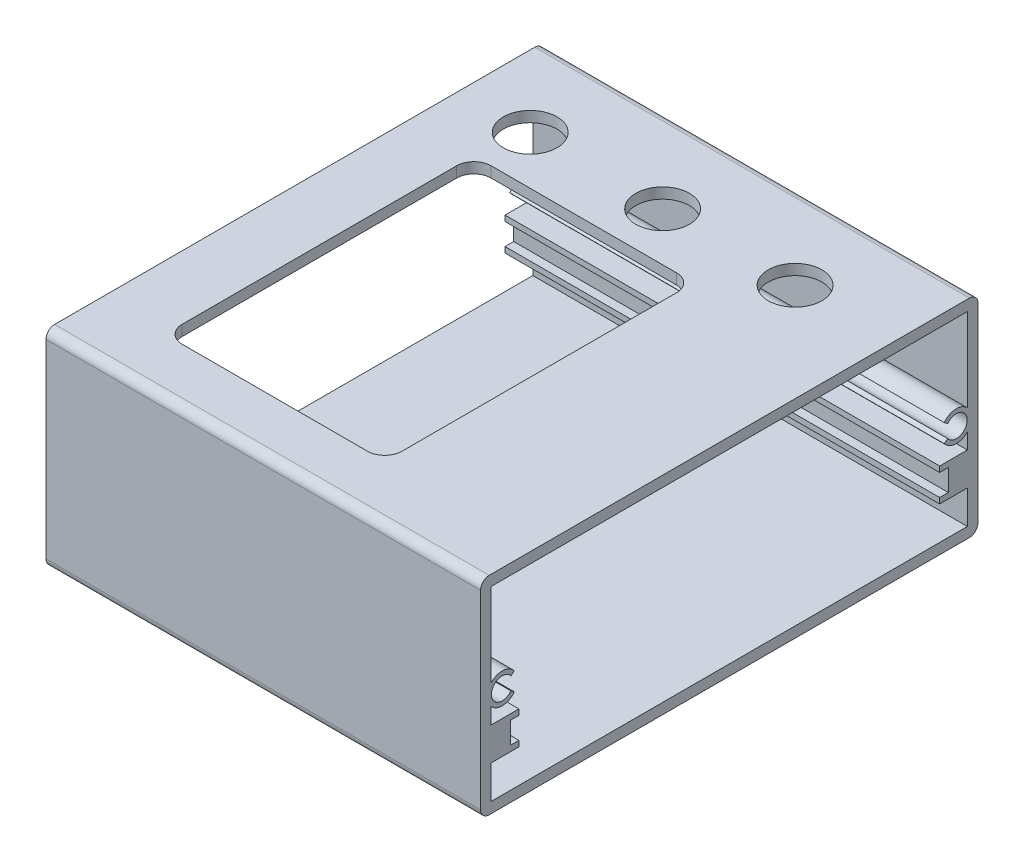
from build123d import *

# Parameters (mm, degrees)
SKETCH1_W           = 57.46
SKETCH1_H           = 23.96
BOSS_EXTRUDE1_DEPTH = 50.2
FILLET1_R           = 1
CUT_EXTRUDE1_REACH  = 25.96
SKETCH2_R           = 3.1
SKETCH2_R_2         = 3
CUT_EXTRUDE2_REACH  = 25.96


with BuildPart() as part:
    # Sketch1 → Boss-Extrude1 (new body)
    with BuildSketch(Plane(origin=(0, 0, 0), x_dir=(0, 0, -1), z_dir=(1, 0, 0))):
        Rectangle(SKETCH1_W, SKETCH1_H)
        with BuildLine():
            Line((-27.5, 1.123993355), (-27.5, 10.75))
            Line((-27.5, 10.75), (27.5, 10.75))
            Line((27.5, 10.75), (27.5, 1.123993355))
            ThreePointArc((27.5, 1.123993355), (26.129235481, 1.667096595), (24.83, 0.97))
            Line((24.83, 0.97), (25.23, 0.67))
            ThreePointArc((25.23, 0.67), (27.48, -0.08), (25.23, -0.83))
            Line((25.23, -0.83), (24.83, -1.13))
            ThreePointArc((24.83, -1.13), (26.129235481, -1.827096595), (27.5, -1.283993355))
            Line((27.5, -1.283993355), (27.5, -3.1))
            Line((27.5, -3.1), (24.3, -3.1))
            Line((24.3, -3.1), (24.3, -3.75))
            Line((24.3, -3.75), (25.3, -3.75))
            Line((25.3, -3.75), (25.3, -6.25))
            Line((25.3, -6.25), (24.3, -6.25))
            Line((24.3, -6.25), (24.3, -6.9))
            Line((24.3, -6.9), (27.5, -6.9))
            Line((27.5, -6.9), (27.5, -10.75))
            Line((27.5, -10.75), (-27.5, -10.75))
            Line((-27.5, -10.75), (-27.5, -6.9))
            Line((-27.5, -6.9), (-24.3, -6.9))
            Line((-24.3, -6.9), (-24.3, -6.25))
            Line((-24.3, -6.25), (-25.3, -6.25))
            Line((-25.3, -6.25), (-25.3, -3.75))
            Line((-25.3, -3.75), (-24.3, -3.75))
            Line((-24.3, -3.75), (-24.3, -3.1))
            Line((-24.3, -3.1), (-27.5, -3.1))
            Line((-27.5, -3.1), (-27.5, -1.283993355))
            ThreePointArc((-27.5, -1.283993355), (-26.129235481, -1.827096595), (-24.83, -1.13))
            Line((-24.83, -1.13), (-25.23, -0.83))
            ThreePointArc((-25.23, -0.83), (-27.48, -0.08), (-25.23, 0.67))
            Line((-25.23, 0.67), (-24.83, 0.97))
            ThreePointArc((-24.83, 0.97), (-26.129235481, 1.667096595), (-27.5, 1.123993355))
        make_face(mode=Mode.SUBTRACT)
    extrude(amount=BOSS_EXTRUDE1_DEPTH)

    # Fillet1
    fillet1_edges = [part.edges().sort_by_distance(p)[0] for p in [
        (25.1, 11.98, -28.73),
        (25.1, -11.98, -28.73),
        (25.1, -11.98, 28.73),
        (25.1, 11.98, 28.73),
    ]]
    fillet(fillet1_edges, radius=FILLET1_R)

    # Sketch2 → Cut-Extrude1 (cut, up to next)
    with BuildSketch(Plane(origin=(0, 11.98, 0), x_dir=(1, 0, 0), z_dir=(0, 1, 0)), mode=Mode.PRIVATE) as cut_extrude1_sk1:
        with Locations((8.25, 18.95)):
            Circle(SKETCH2_R)
        with Locations((8.25, 18.95)):
            Circle(SKETCH2_R_2, mode=Mode.SUBTRACT)
    cut_extrude1_tool1 = extrude(cut_extrude1_sk1.sketch, amount=-CUT_EXTRUDE1_REACH, mode=Mode.PRIVATE) & part.part
    add(cut_extrude1_tool1.solids().sort_by_distance((5.237681, 11.98, -18.95))[0], mode=Mode.SUBTRACT)
    # Sketch2 → Cut-Extrude1 (cut, up to next)
    with BuildSketch(Plane(origin=(0, 11.98, 0), x_dir=(1, 0, 0), z_dir=(0, 1, 0)), mode=Mode.PRIVATE) as cut_extrude1_sk2:
        with Locations((8.25, 18.95)):
            Circle(SKETCH2_R_2)
    cut_extrude1_tool2 = extrude(cut_extrude1_sk2.sketch, amount=-CUT_EXTRUDE1_REACH, mode=Mode.PRIVATE) & part.part
    add(cut_extrude1_tool2.solids().sort_by_distance((8.25, 11.98, -18.95))[0], mode=Mode.SUBTRACT)
    # Sketch2 → Cut-Extrude1 (cut, up to next)
    with BuildSketch(Plane(origin=(0, 11.98, 0), x_dir=(1, 0, 0), z_dir=(0, 1, 0)), mode=Mode.PRIVATE) as cut_extrude1_sk3:
        with Locations((23.55, 18.95)):
            Circle(SKETCH2_R)
        with Locations((23.55, 18.95)):
            Circle(SKETCH2_R_2, mode=Mode.SUBTRACT)
    cut_extrude1_tool3 = extrude(cut_extrude1_sk3.sketch, amount=-CUT_EXTRUDE1_REACH, mode=Mode.PRIVATE) & part.part
    add(cut_extrude1_tool3.solids().sort_by_distance((20.537681, 11.98, -18.95))[0], mode=Mode.SUBTRACT)
    # Sketch2 → Cut-Extrude1 (cut, up to next)
    with BuildSketch(Plane(origin=(0, 11.98, 0), x_dir=(1, 0, 0), z_dir=(0, 1, 0)), mode=Mode.PRIVATE) as cut_extrude1_sk4:
        with Locations((23.55, 18.95)):
            Circle(SKETCH2_R_2)
    cut_extrude1_tool4 = extrude(cut_extrude1_sk4.sketch, amount=-CUT_EXTRUDE1_REACH, mode=Mode.PRIVATE) & part.part
    add(cut_extrude1_tool4.solids().sort_by_distance((23.55, 11.98, -18.95))[0], mode=Mode.SUBTRACT)
    # Sketch2 → Cut-Extrude1 (cut, up to next)
    with BuildSketch(Plane(origin=(0, 11.98, 0), x_dir=(1, 0, 0), z_dir=(0, 1, 0)), mode=Mode.PRIVATE) as cut_extrude1_sk5:
        with Locations((38.85, 18.95)):
            Circle(SKETCH2_R)
        with Locations((38.85, 18.95)):
            Circle(SKETCH2_R_2, mode=Mode.SUBTRACT)
    cut_extrude1_tool5 = extrude(cut_extrude1_sk5.sketch, amount=-CUT_EXTRUDE1_REACH, mode=Mode.PRIVATE) & part.part
    add(cut_extrude1_tool5.solids().sort_by_distance((35.837681, 11.98, -18.95))[0], mode=Mode.SUBTRACT)
    # Sketch2 → Cut-Extrude1 (cut, up to next)
    with BuildSketch(Plane(origin=(0, 11.98, 0), x_dir=(1, 0, 0), z_dir=(0, 1, 0)), mode=Mode.PRIVATE) as cut_extrude1_sk6:
        with Locations((38.85, 18.95)):
            Circle(SKETCH2_R_2)
    cut_extrude1_tool6 = extrude(cut_extrude1_sk6.sketch, amount=-CUT_EXTRUDE1_REACH, mode=Mode.PRIVATE) & part.part
    add(cut_extrude1_tool6.solids().sort_by_distance((38.85, 11.98, -18.95))[0], mode=Mode.SUBTRACT)

    # Sketch3 → Cut-Extrude2 (cut, up to next)
    with BuildSketch(Plane(origin=(0, 11.98, 0), x_dir=(1, 0, 0), z_dir=(0, 1, 0)), mode=Mode.PRIVATE) as cut_extrude2_sk1:
        with BuildLine():
            Line((7.35, 11.35), (7.35, -20.35))
            ThreePointArc((7.35, -20.35), (7.935786438, -21.764213562), (9.35, -22.35))
            Line((9.35, -22.35), (30.75, -22.35))
            ThreePointArc((30.75, -22.35), (32.164213562, -21.764213562), (32.75, -20.35))
            Line((32.75, -20.35), (32.75, 11.35))
            ThreePointArc((32.75, 11.35), (32.164213562, 12.764213562), (30.75, 13.35))
            Line((30.75, 13.35), (9.35, 13.35))
            ThreePointArc((9.35, 13.35), (7.935786438, 12.764213562), (7.35, 11.35))
        make_face()
    cut_extrude2_tool1 = extrude(cut_extrude2_sk1.sketch, amount=-CUT_EXTRUDE2_REACH, mode=Mode.PRIVATE) & part.part
    add(cut_extrude2_tool1.solids().sort_by_distance((20.05, 11.98, 4.5))[0], mode=Mode.SUBTRACT)


solid = part.part
